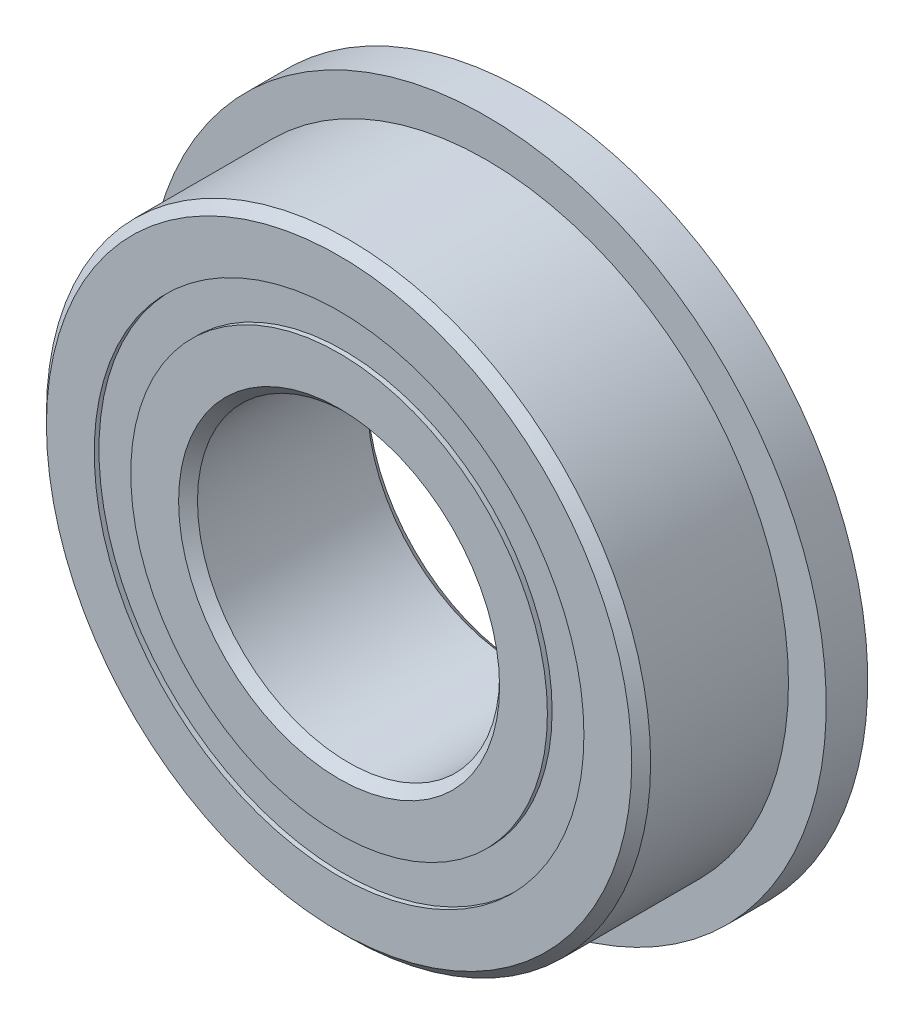
from build123d import *

# Parameters (mm, degrees)
CIRPATTERN1_COUNT = 12
SKETCH5_W         = 1.163242561
SKETCH5_H         = 0.967032968
SKETCH6_W         = 1.1
SKETCH6_H         = 2.516483516


with BuildPart() as part:
    # Sketch1 → Revolve1 (revolve)
    with BuildSketch(Plane(origin=(0, 0, 0), x_dir=(0, 0, -1), z_dir=(1, 0, 0))):
        with BuildLine():
            Line((2.25, 8), (-2.25, 8))
            Line((-2.25, 8), (-2.5, 7.75))
            Line((-2.5, 7.75), (-2.5, 6.483516484))
            Line((-2.5, 6.483516484), (-1.111111111, 6.483516484))
            ThreePointArc((-1.111111111, 6.483516484), (0, 7.211757439), (1.111111111, 6.483516484))
            Line((1.111111111, 6.483516484), (2.5, 6.483516484))
            Line((2.5, 6.483516484), (2.5, 7.75))
            Line((2.5, 7.75), (2.25, 8))
        make_face()
    revolve(axis=Axis((0, 0, 2.5), (0, 0, -1)))

    # Sketch6 → Revolve6 (revolve)
    with BuildSketch(Plane(origin=(0, 0, 0), x_dir=(0, 0, -1), z_dir=(1, 0, 0))):
        with Locations((1.95, 7.741758242)):
            Rectangle(SKETCH6_W, SKETCH6_H)
    revolve(axis=Axis((0, 0, -2.5), (0, 0, 1)))


with BuildPart() as body_2:
    # Sketch3 → Revolve3 (revolve)
    with BuildSketch(Plane(origin=(0, 0, 0), x_dir=(0, 0, -1), z_dir=(1, 0, 0))):
        with BuildLine():
            Line((-2.5, 5.516483516), (-1.111111111, 5.516483516))
            ThreePointArc((-1.111111111, 5.516483516), (0, 4.788242561), (1.111111111, 5.516483516))
            Line((1.111111111, 5.516483516), (2.5, 5.516483516))
            Line((2.5, 5.516483516), (2.5, 4.25))
            Line((2.5, 4.25), (2.25, 4))
            Line((2.25, 4), (-2.25, 4))
            Line((-2.25, 4), (-2.5, 4.25))
            Line((-2.5, 4.25), (-2.5, 5.516483516))
        make_face()
    revolve(axis=Axis((0, 0, 2.5), (0, 0, -1)))


with BuildPart() as body_3:
    # Sketch4 → Revolve4 (revolve)
    with BuildSketch(Plane(origin=(0, 0, 0), x_dir=(0, 0, -1), z_dir=(1, 0, 0))):
        with BuildLine():
            Line((-1.211757439, 6), (1.211757439, 6))
            ThreePointArc((1.211757439, 6), (0, 7.211757439), (-1.211757439, 6))
        make_face()
    revolve(axis=Axis((0, 6, 1.211757439), (0, 0, -1)))


with BuildPart() as cirpattern1_1:
    # CirPattern1: pattern copy
    add(body_3.part.rotate(Axis((0, 0, -2.5), (0, 0, 1)), 1 * 360 / CIRPATTERN1_COUNT))


with BuildPart() as cirpattern1_2:
    # CirPattern1: pattern copy
    add(body_3.part.rotate(Axis((0, 0, -2.5), (0, 0, 1)), 2 * 360 / CIRPATTERN1_COUNT))


with BuildPart() as cirpattern1_3:
    # CirPattern1: pattern copy
    add(body_3.part.rotate(Axis((0, 0, -2.5), (0, 0, 1)), 3 * 360 / CIRPATTERN1_COUNT))


with BuildPart() as cirpattern1_4:
    # CirPattern1: pattern copy
    add(body_3.part.rotate(Axis((0, 0, -2.5), (0, 0, 1)), 4 * 360 / CIRPATTERN1_COUNT))


with BuildPart() as cirpattern1_5:
    # CirPattern1: pattern copy
    add(body_3.part.rotate(Axis((0, 0, -2.5), (0, 0, 1)), 5 * 360 / CIRPATTERN1_COUNT))


with BuildPart() as cirpattern1_6:
    # CirPattern1: pattern copy
    add(body_3.part.rotate(Axis((0, 0, -2.5), (0, 0, 1)), 6 * 360 / CIRPATTERN1_COUNT))


with BuildPart() as cirpattern1_7:
    # CirPattern1: pattern copy
    add(body_3.part.rotate(Axis((0, 0, -2.5), (0, 0, 1)), 7 * 360 / CIRPATTERN1_COUNT))


with BuildPart() as cirpattern1_8:
    # CirPattern1: pattern copy
    add(body_3.part.rotate(Axis((0, 0, -2.5), (0, 0, 1)), 8 * 360 / CIRPATTERN1_COUNT))


with BuildPart() as cirpattern1_9:
    # CirPattern1: pattern copy
    add(body_3.part.rotate(Axis((0, 0, -2.5), (0, 0, 1)), 9 * 360 / CIRPATTERN1_COUNT))


with BuildPart() as cirpattern1_10:
    # CirPattern1: pattern copy
    add(body_3.part.rotate(Axis((0, 0, -2.5), (0, 0, 1)), 10 * 360 / CIRPATTERN1_COUNT))


with BuildPart() as cirpattern1_11:
    # CirPattern1: pattern copy
    add(body_3.part.rotate(Axis((0, 0, -2.5), (0, 0, 1)), 11 * 360 / CIRPATTERN1_COUNT))


with BuildPart() as body_15:
    # Sketch5 → Revolve5 (revolve)
    with BuildSketch(Plane(origin=(0, 0, 0), x_dir=(0, 0, -1), z_dir=(1, 0, 0))):
        with Locations((-1.79337872, 6)):
            Rectangle(SKETCH5_W, SKETCH5_H)
        with Locations((1.79337872, 6)):
            Rectangle(SKETCH5_W, SKETCH5_H)
    revolve(axis=Axis((0, 0, 2.5), (0, 0, -1)))


solid = Compound([part.part, body_2.part, body_3.part, cirpattern1_1.part, cirpattern1_2.part, cirpattern1_3.part, cirpattern1_4.part, cirpattern1_5.part, cirpattern1_6.part, cirpattern1_7.part, cirpattern1_8.part, cirpattern1_9.part, cirpattern1_10.part, cirpattern1_11.part, body_15.part])
